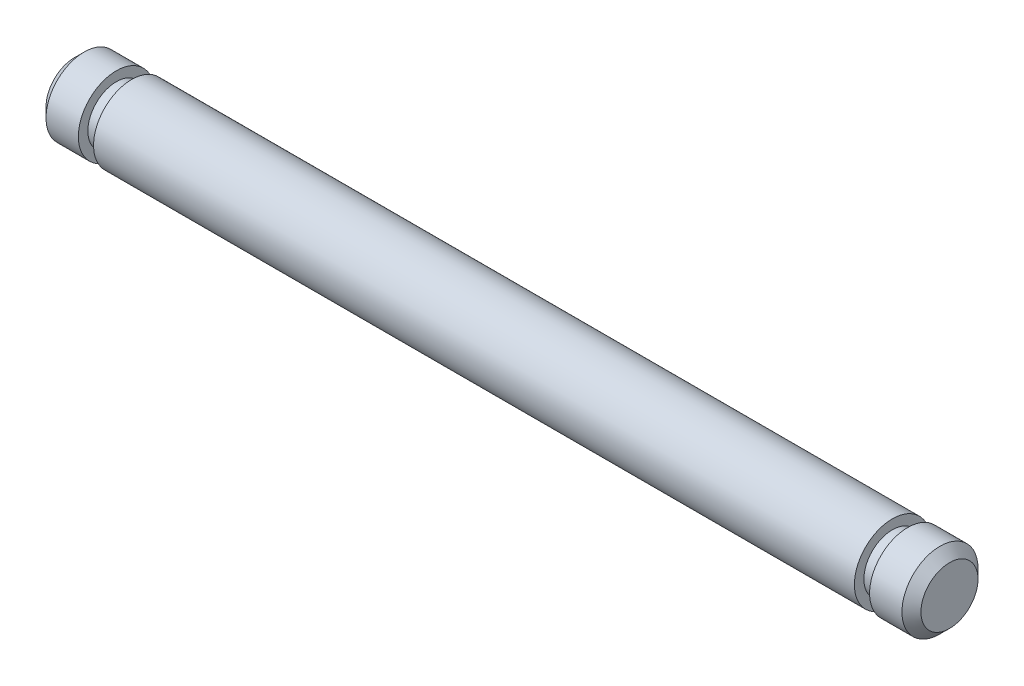
from build123d import *

# Parameters (mm, degrees)
SKETCH1_R           = 2
BOSS_EXTRUDE1_DEPTH = 23
CHAMFER1_SIZE       = 0.5
CUT_EXTRUDE1_START  = -3
SKETCH2_R           = 2
SKETCH2_R_2         = 1.5
CUT_EXTRUDE1_DEPTH  = 0.8


with BuildPart() as part:
    # Sketch1 → Boss-Extrude1 (new body, symmetric)
    with BuildSketch(Plane(origin=(0, 0, 0), x_dir=(0, 0, -1), z_dir=(1, 0, 0))):
        Circle(SKETCH1_R)
    extrude(amount=BOSS_EXTRUDE1_DEPTH, both=True)

    # Chamfer1
    chamfer1_edges = [part.edges().sort_by_distance(p)[0] for p in [
        (-23, 0, 2),
        (23, 0, 2),
    ]]
    chamfer(chamfer1_edges, length=CHAMFER1_SIZE)

    # Sketch2 → Cut-Extrude1 (cut)
    with BuildSketch(Plane(origin=(23, 0, 0), x_dir=(0, 0, -1), z_dir=(1, 0, 0)).offset(CUT_EXTRUDE1_START)):
        Circle(SKETCH2_R)
        Circle(SKETCH2_R_2, mode=Mode.SUBTRACT)
    cut_extrude1 = extrude(amount=CUT_EXTRUDE1_DEPTH, mode=Mode.SUBTRACT)

    # Mirror1: Cut-Extrude1 across plane
    add(cut_extrude1.mirror(Plane(origin=(0, 0, 0), x_dir=(0, 0, 1), z_dir=(1, 0, 0))), mode=Mode.SUBTRACT)


solid = part.part
